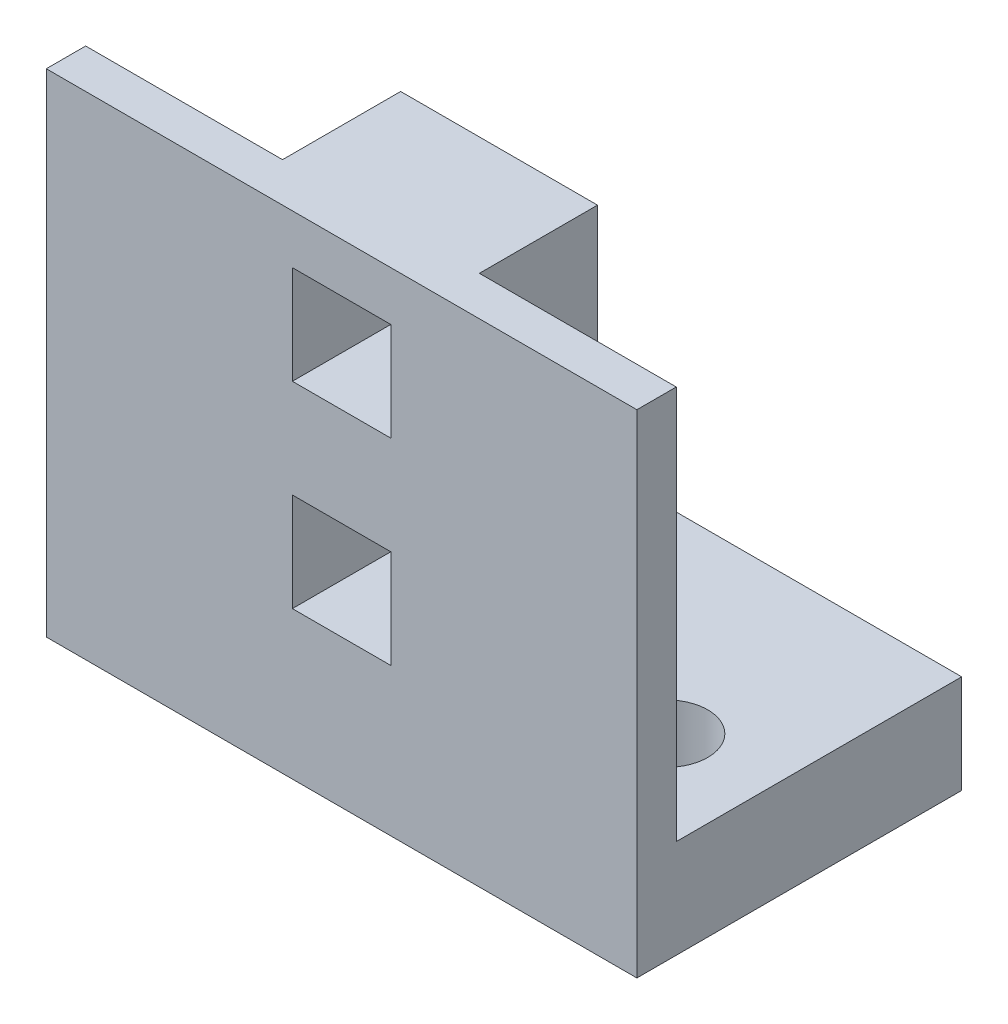
from build123d import *

# Parameters (mm, degrees)
SKETCH1_W           = 30
SKETCH1_H           = 16.5
SKETCH1_R           = 2.1
BOSS_EXTRUDE1_DEPTH = 5
SKETCH2_W           = 30
SKETCH2_H           = 20
BOSS_EXTRUDE2_DEPTH = 2
SKETCH3_W           = 5
SKETCH3_H           = 5
CUT_EXTRUDE1_DEPTH  = 3
SKETCH4_W           = 10
SKETCH4_H           = 20
SKETCH4_W_2         = 5
SKETCH4_H_2         = 5
BOSS_EXTRUDE3_DEPTH = 4
SKETCH5_W           = 10
SKETCH5_H           = 20
BOSS_EXTRUDE4_DEPTH = 2


with BuildPart() as part:
    # Sketch1 → Boss-Extrude1 (new body)
    with BuildSketch(Plane(origin=(0, 0, 0), x_dir=(1, 0, 0), z_dir=(0, 1, 0))):
        Rectangle(SKETCH1_W, SKETCH1_H)
        with Locations((-10, -1.75)):
            Circle(SKETCH1_R, mode=Mode.SUBTRACT)
        with Locations((10, -1.75)):
            Circle(SKETCH1_R, mode=Mode.SUBTRACT)
    extrude(amount=BOSS_EXTRUDE1_DEPTH)

    # Sketch2 → Boss-Extrude2 (add)
    with BuildSketch(Plane.XY.offset(8.25)):
        with Locations((0, 15)):
            Rectangle(SKETCH2_W, SKETCH2_H)
    extrude(amount=-BOSS_EXTRUDE2_DEPTH)

    # Sketch3 → Cut-Extrude1 (cut, through all)
    with BuildSketch(Plane(origin=(0, 0, 6.25), x_dir=(-1, 0, 0), z_dir=(0, 0, -1))):
        with Locations((0, 10)):
            Rectangle(SKETCH3_W, SKETCH3_H)
        with Locations((0, 20)):
            Rectangle(SKETCH3_W, SKETCH3_H)
    extrude(amount=-CUT_EXTRUDE1_DEPTH, mode=Mode.SUBTRACT)

    # Sketch4 → Boss-Extrude3 (add)
    with BuildSketch(Plane(origin=(0, 0, 6.25), x_dir=(-1, 0, 0), z_dir=(0, 0, -1))):
        with Locations((0, 15)):
            Rectangle(SKETCH4_W, SKETCH4_H)
        with Locations((0, 20)):
            Rectangle(SKETCH4_W_2, SKETCH4_H_2, mode=Mode.SUBTRACT)
        with Locations((0, 10)):
            Rectangle(SKETCH4_W_2, SKETCH4_H_2, mode=Mode.SUBTRACT)
    extrude(amount=BOSS_EXTRUDE3_DEPTH)

    # Sketch5 → Boss-Extrude4 (add)
    with BuildSketch(Plane(origin=(0, 0, 2.25), x_dir=(-1, 0, 0), z_dir=(0, 0, -1))):
        with Locations((0, 15)):
            Rectangle(SKETCH5_W, SKETCH5_H)
    extrude(amount=BOSS_EXTRUDE4_DEPTH)


solid = part.part
